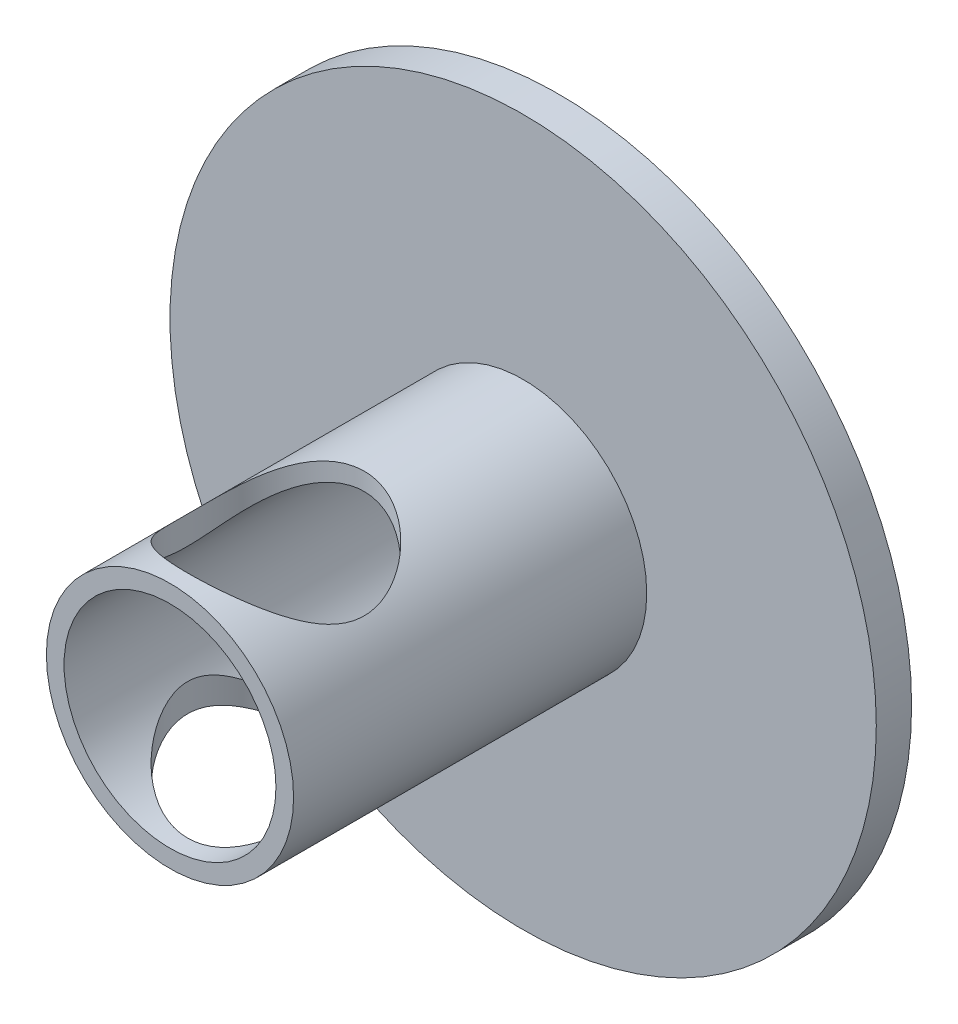
from build123d import *

# Parameters (mm, degrees)
CROQUIS1_R              = 10
SALIENTE_EXTRUIR1_DEPTH = 1
CROQUIS2_R              = 3.5
SALIENTE_EXTRUIR2_DEPTH = 10
CROQUIS3_R              = 3
CORTAR_EXTRUIR1_DEPTH   = 10
CORTAR_EXTRUIR2_DEPTH   = 10


with BuildPart() as part:
    # Croquis1 → Saliente-Extruir1 (new body)
    with BuildSketch(Plane.XY):
        Circle(CROQUIS1_R)
    extrude(amount=SALIENTE_EXTRUIR1_DEPTH)

    # Croquis2 → Saliente-Extruir2 (add)
    with BuildSketch(Plane.XY.offset(1)):
        Circle(CROQUIS2_R)
    extrude(amount=SALIENTE_EXTRUIR2_DEPTH)

    # Croquis3 → Cortar-Extruir1 (cut)
    with BuildSketch(Plane.XY.offset(11)):
        Circle(CROQUIS3_R)
    extrude(amount=-CORTAR_EXTRUIR1_DEPTH, mode=Mode.SUBTRACT)

    # Croquis4 → Cortar-Extruir2 (cut)
    with BuildSketch(Plane(origin=(0, 0, 0), x_dir=(1, 0, 0), z_dir=(0, 1, 0))):
        with BuildLine():
            ThreePointArc((1.25, -5.834936491), (0, -5.5), (-1.25, -5.834936491))
            ThreePointArc((-1.25, -5.834936491), (-1.833451245, -6.300454022), (-2.253469547, -6.917468245))
            ThreePointArc((-2.253469547, -6.917468245), (-2.5, -8), (-2.253469547, -9.082531755))
            ThreePointArc((-2.253469547, -9.082531755), (-1.833451245, -9.699545978), (-1.25, -10.165063509))
            ThreePointArc((-1.25, -10.165063509), (0, -10.5), (1.25, -10.165063509))
            ThreePointArc((1.25, -10.165063509), (1.833451245, -9.699545978), (2.253469547, -9.082531755))
            ThreePointArc((2.253469547, -9.082531755), (2.5, -8), (2.253469547, -6.917468245))
            ThreePointArc((2.253469547, -6.917468245), (1.833451245, -6.300454022), (1.25, -5.834936491))
        make_face()
    cortar_extruir2 = extrude(amount=-CORTAR_EXTRUIR2_DEPTH, mode=Mode.SUBTRACT)

    # Simetría1: Cortar-Extruir2 across plane
    add(cortar_extruir2.mirror(Plane.ZX), mode=Mode.SUBTRACT)


solid = part.part
